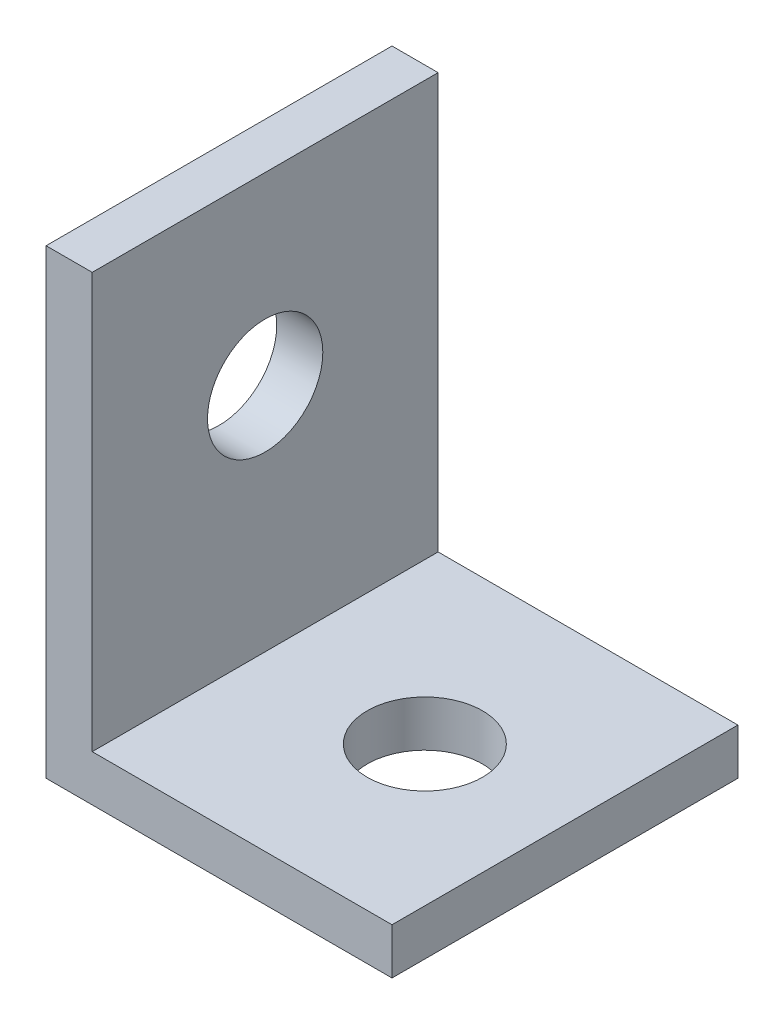
from build123d import *

# Parameters (mm, degrees)
BOSS_EXTRUDE2_DEPTH = 19.05
SKETCH3_R           = 3.175
CUT_EXTRUDE1_DEPTH  = 19.05
SKETCH4_R           = 3.175
CUT_EXTRUDE2_DEPTH  = 19.05


with BuildPart() as part:
    # Sketch2 → Boss-Extrude2 (new body)
    with BuildSketch(Plane.XY):
        Polygon((0, 0), (0, 25.4), (2.54, 25.4), (2.54, 2.54), (19.05, 2.54), (19.05, 0), align=None)
    extrude(amount=BOSS_EXTRUDE2_DEPTH)

    # Sketch3 → Cut-Extrude1 (cut)
    with BuildSketch(Plane(origin=(2.54, 0, 0), x_dir=(0, 0, -1), z_dir=(1, 0, 0))):
        with Locations((-9.525, 15.24)):
            Circle(SKETCH3_R)
    extrude(amount=-CUT_EXTRUDE1_DEPTH, mode=Mode.SUBTRACT)

    # Sketch4 → Cut-Extrude2 (cut)
    with BuildSketch(Plane(origin=(0, 2.54, 0), x_dir=(1, 0, 0), z_dir=(0, 1, 0))):
        with Locations((11.334166685, -9.525)):
            Circle(SKETCH4_R)
    extrude(amount=-CUT_EXTRUDE2_DEPTH, mode=Mode.SUBTRACT)


solid = part.part
